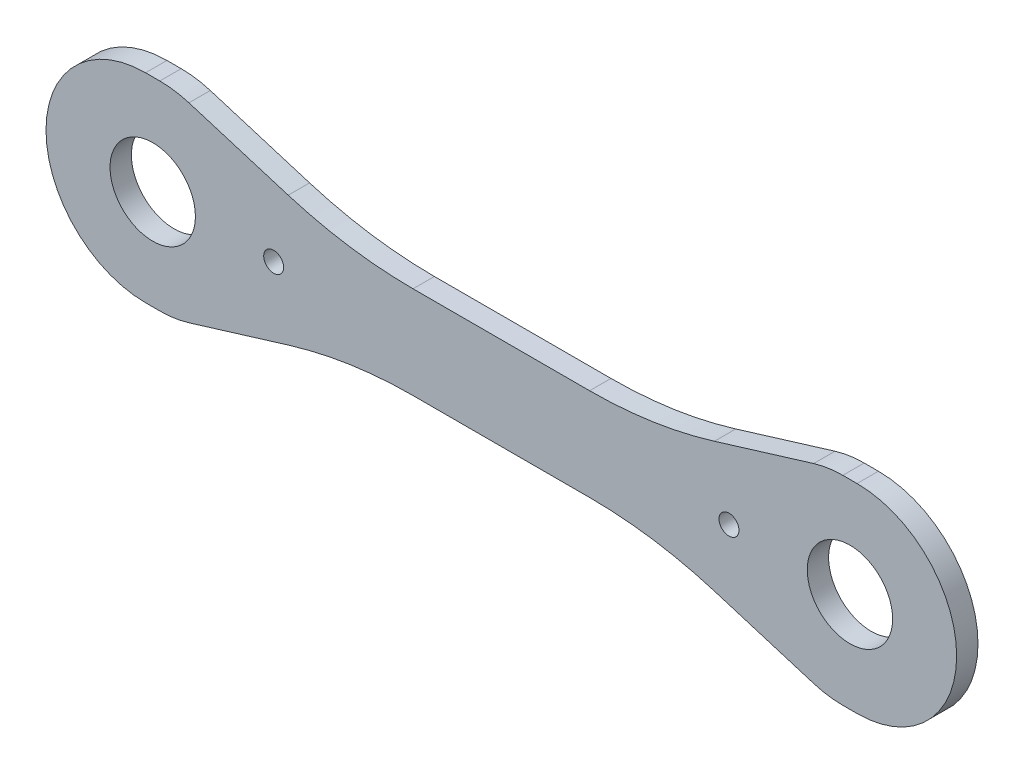
from build123d import *

# Parameters (mm, degrees)
EXTRUDE1_DEPTH         = 15
SKETCH2_R              = 30
F_60_UDBORINGER_DEPTH  = 16
SKETCH3_R              = 7
M16_GEVINDHULLER_DEPTH = 16


with BuildPart() as part:
    # Sketch1 → Extrude1 (new body)
    with BuildSketch(Plane.XY):
        with BuildLine():
            Line((-250, 70), (-240, 70))
            ThreePointArc((-240, 70), (-229.653341221, 69.231110435), (-219.533980669, 66.941332917))
            Line((-219.533980669, 66.941332917), (-149.757667724, 45.608573211))
            ThreePointArc((-149.757667724, 45.608573211), (-106.388979647, 35.795240991), (-62.046156308, 32.5))
            Line((-62.046156308, 32.5), (62.046156308, 32.5))
            ThreePointArc((62.046156308, 32.5), (106.388979647, 35.795240991), (149.757667724, 45.608573211))
            Line((149.757667724, 45.608573211), (219.533980669, 66.941332917))
            ThreePointArc((219.533980669, 66.941332917), (229.653341221, 69.231110435), (240, 70))
            Line((240, 70), (250, 70))
            ThreePointArc((250, 70), (320, 0), (250, -70))
            Line((250, -70), (240, -70))
            ThreePointArc((240, -70), (229.653341221, -69.231110435), (219.533980669, -66.941332917))
            Line((219.533980669, -66.941332917), (149.757667724, -45.608573211))
            ThreePointArc((149.757667724, -45.608573211), (106.388979647, -35.795240991), (62.046156308, -32.5))
            Line((62.046156308, -32.5), (-62.046156308, -32.5))
            ThreePointArc((-62.046156308, -32.5), (-106.388979647, -35.795240991), (-149.757667724, -45.608573211))
            Line((-149.757667724, -45.608573211), (-219.533980669, -66.941332917))
            ThreePointArc((-219.533980669, -66.941332917), (-229.653341221, -69.231110435), (-240, -70))
            Line((-240, -70), (-250, -70))
            ThreePointArc((-250, -70), (-320, 0), (-250, 70))
        make_face()
    extrude(amount=EXTRUDE1_DEPTH)

    # Sketch2 → ø60 udboringer (cut, through all)
    with BuildSketch(Plane.XY.offset(15)):
        with Locations((245, 0)):
            Circle(SKETCH2_R)
        with Locations((-245, 0)):
            Circle(SKETCH2_R)
    extrude(amount=-F_60_UDBORINGER_DEPTH, mode=Mode.SUBTRACT)

    # Sketch3 → M16 gevindhuller (cut, through all)
    with BuildSketch(Plane.XY.offset(15)):
        with Locations((160, 0)):
            Circle(SKETCH3_R)
        with Locations((-160, 0)):
            Circle(SKETCH3_R)
    extrude(amount=-M16_GEVINDHULLER_DEPTH, mode=Mode.SUBTRACT)


solid = part.part
